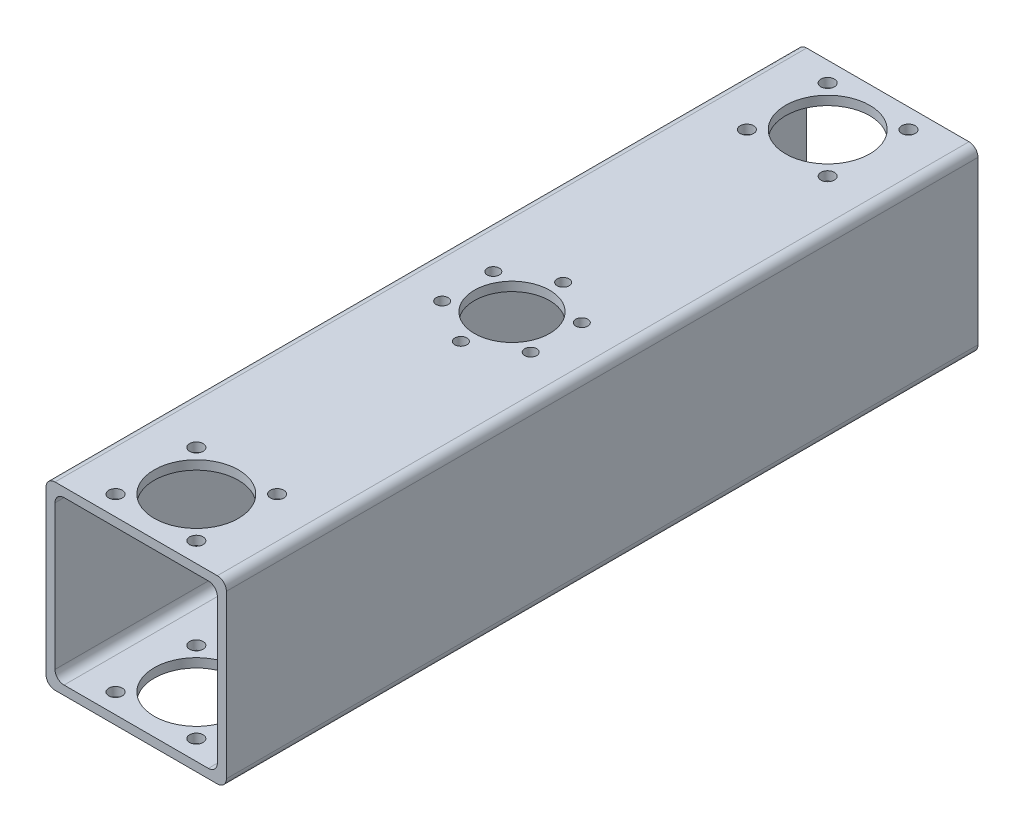
from build123d import *

# Parameters (mm, degrees)
SKETCH1_W               = 60
SKETCH1_H               = 60
SKETCH1_W_2             = 54
SKETCH1_H_2             = 54
BOSS_EXTRUDE1_DEPTH     = 250
FILLET1_R               = 3
SKETCH2_R               = 2
SKETCH2_R_2             = 2.25
SKETCH2_R_3             = 12.5
SKETCH2_R_4             = 14
CUT_EXTRUDE1_DEPTH      = 31
CUT_EXTRUDE1_DEPTH_BACK = 31


with BuildPart() as part:
    # Sketch1 → Boss-Extrude1 (new body)
    with BuildSketch(Plane.XY):
        Rectangle(SKETCH1_W, SKETCH1_H)
        Rectangle(SKETCH1_W_2, SKETCH1_H_2, mode=Mode.SUBTRACT)
    extrude(amount=BOSS_EXTRUDE1_DEPTH)

    # Fillet1
    fillet1_edges = [part.edges().sort_by_distance(p)[0] for p in [
        (27, -27, 125),
        (27, 27, 125),
        (-27, 27, 125),
        (-27, -27, 125),
        (30, -30, 125),
        (-30, -30, 125),
        (-30, 30, 125),
        (30, 30, 125),
    ]]
    fillet(fillet1_edges, radius=FILLET1_R)

    # Sketch2 → Cut-Extrude1 (cut, two sides)
    with BuildSketch(Plane(origin=(0, 0, 0), x_dir=(1, 0, 0), z_dir=(0, 1, 0))) as cut_extrude1_sk:
        with Locations((0, -142)):
            Circle(SKETCH2_R)
        with Locations((-14.722431864, -133.5)):
            Circle(SKETCH2_R)
        with Locations((-14.722431864, -116.5)):
            Circle(SKETCH2_R)
        with Locations((0, -108)):
            Circle(SKETCH2_R)
        with Locations((14.722431864, -116.5)):
            Circle(SKETCH2_R)
        with Locations((14.722431864, -133.5)):
            Circle(SKETCH2_R)
        with Locations((-13.435028843, -216.564971157)):
            Circle(SKETCH2_R_2)
        with Locations((13.435028843, -216.564971157)):
            Circle(SKETCH2_R_2)
        with Locations((13.435028843, -243.435028843)):
            Circle(SKETCH2_R_2)
        with Locations((-13.435028843, -243.435028843)):
            Circle(SKETCH2_R_2)
        with Locations((-13.435028843, -6.564971157)):
            Circle(SKETCH2_R_2)
        with Locations((13.435028843, -6.564971157)):
            Circle(SKETCH2_R_2)
        with Locations((13.435028843, -33.435028843)):
            Circle(SKETCH2_R_2)
        with Locations((-13.435028843, -33.435028843)):
            Circle(SKETCH2_R_2)
        with Locations((0, -125)):
            Circle(SKETCH2_R_3)
        with Locations((0, -230)):
            Circle(SKETCH2_R_4)
        with Locations((0, -20)):
            Circle(SKETCH2_R_4)
    extrude(amount=CUT_EXTRUDE1_DEPTH, mode=Mode.SUBTRACT)
    extrude(cut_extrude1_sk.sketch, amount=-CUT_EXTRUDE1_DEPTH_BACK, mode=Mode.SUBTRACT)


solid = part.part
